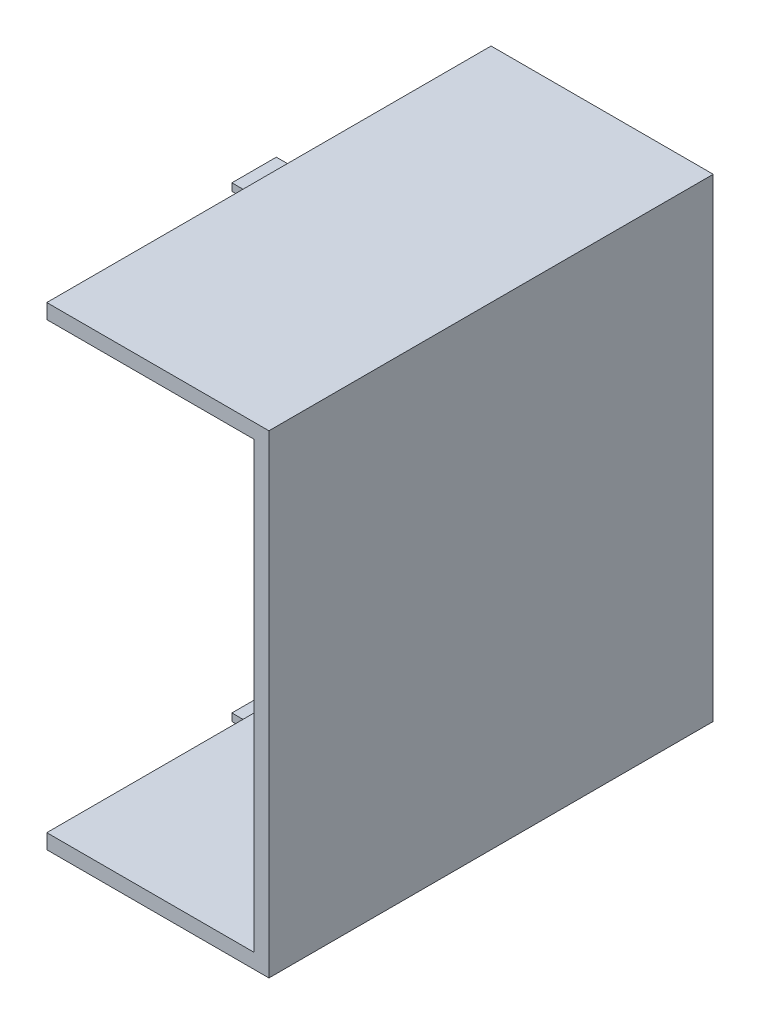
from build123d import *

# Parameters (mm, degrees)
BOSS_EXTRUDE1_DEPTH = 15
SKETCH2_W           = 3
SKETCH2_H           = 0.5
BOSS_EXTRUDE2_DEPTH = 1
SKETCH3_W           = 3
SKETCH3_H           = 0.5
BOSS_EXTRUDE3_DEPTH = 1


with BuildPart() as part:
    # Sketch1 → Boss-Extrude1 (new body, symmetric)
    with BuildSketch(Plane.XY):
        Polygon((0, 0), (15, 0), (15, 32), (0, 32), (0, 31), (14, 31), (14, 1), (0, 1), align=None)
    extrude(amount=BOSS_EXTRUDE1_DEPTH, both=True)

    # Sketch2 → Boss-Extrude2 (add)
    with BuildSketch(Plane.ZY):
        with Locations((0, 31.5)):
            Rectangle(SKETCH2_W, SKETCH2_H)
    extrude(amount=BOSS_EXTRUDE2_DEPTH)

    # Sketch3 → Boss-Extrude3 (add)
    with BuildSketch(Plane.ZY):
        with Locations((0, 0.5)):
            Rectangle(SKETCH3_W, SKETCH3_H)
    extrude(amount=BOSS_EXTRUDE3_DEPTH)


solid = part.part
